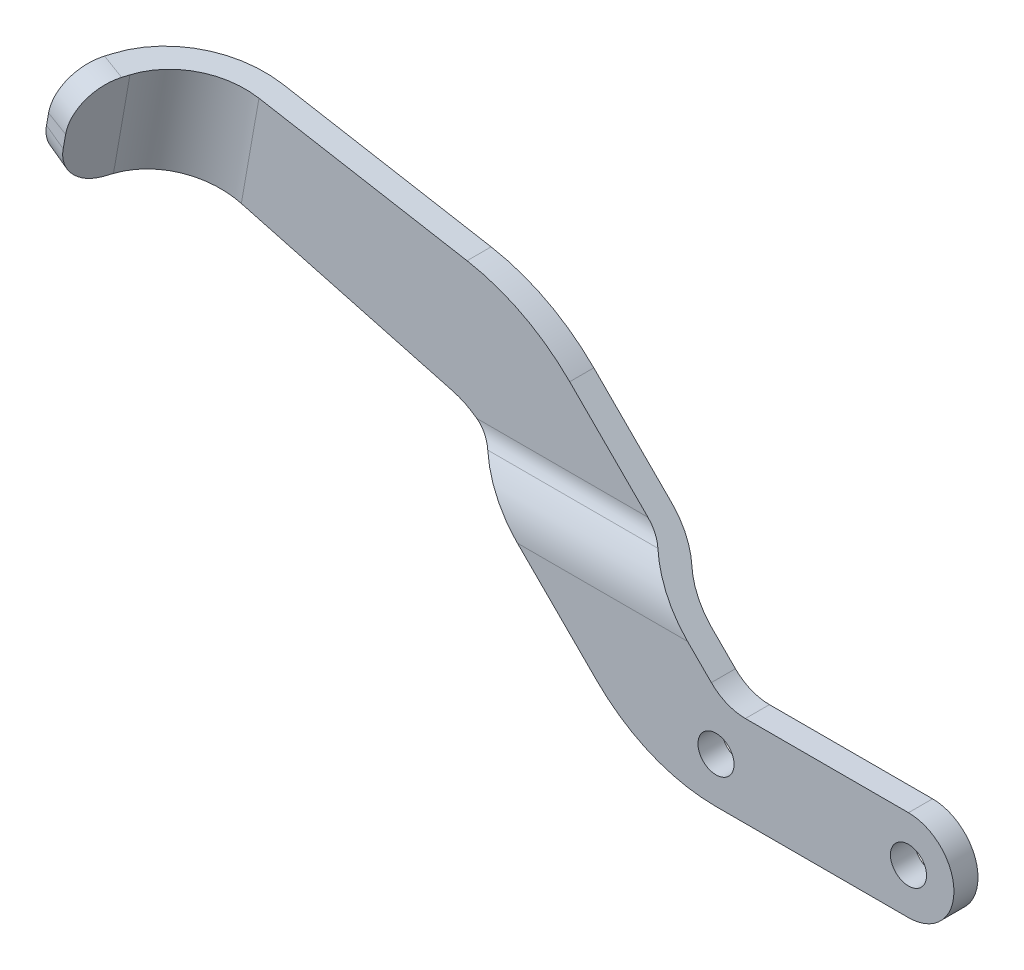
from build123d import *

# Parameters (mm, degrees)
BASE_EXTRUDE_DEPTH      = 3.175
CUT_EXTRUDE1_DEPTH      = 101.324569797
CUT_EXTRUDE1_DEPTH_BACK = 101.324569797
CUT_EXTRUDE2_DEPTH      = 101.3245698
SKETCH4_R               = 2.38125
CUT_EXTRUDE3_DEPTH      = 101.47517694
BOSS_EXTRUDE1_REACH     = 102.663
FILLET4_R               = 5.334


with BuildPart() as part:
    # Sketch1 → Base-Extrude (new, symmetric)
    with BuildSketch(Plane.XY):
        with BuildLine():
            Line((0, 6), (-21.525, 6))
            ThreePointArc((-21.525, 6), (-23.955039796, 6.483364969), (-26.015128061, 7.859871939))
            Line((-26.015128061, 7.859871939), (-47.883548214, 29.728292093))
            ThreePointArc((-47.883548214, 29.728292093), (-54.11564568, 34.297855014), (-61.433396744, 36.781896777))
            Line((-61.433396744, 36.781896777), (-88.9, 41.625))
            Line((-88.9, 41.625), (-91.226630185, 28.43002453))
            Line((-91.226630185, 28.43002453), (-63.378809052, 20.968223346))
            ThreePointArc((-63.378809052, 20.968223346), (-61.081560456, 20.016671822), (-59.108868366, 18.502971942))
            Line((-59.108868366, 18.502971942), (-41.115448212, 0.509551788))
            ThreePointArc((-41.115448212, 0.509551788), (-33.905139284, -4.30822261), (-25.4, -6))
            Line((-25.4, -6), (0, -6))
            ThreePointArc((0, -6), (6, 0), (0, 6))
        make_face()
    extrude(amount=BASE_EXTRUDE_DEPTH, both=True)

    # Sketch2 → Cut-Extrude1 (cut, two sides)
    with BuildSketch(Plane(origin=(0, 0, 0), x_dir=(0, 0, -1), z_dir=(1, 0, 0))) as cut_extrude1_sk:
        with BuildLine():
            Line((109.267936785, -6), (3.175, -6))
            Line((3.175, -6), (0, -6))
            Line((0, -6), (0, 10.999739587))
            ThreePointArc((0, 10.999739587), (0.410118898, 13.244803618), (1.5875, 15.199869794))
            ThreePointArc((1.5875, 15.199869794), (2.764881102, 17.15493597), (3.175, 19.4))
            Line((3.175, 19.4), (3.175, 125.492936785))
            Line((3.175, 125.492936785), (168.312411522, 258.731370649))
            Line((168.312411522, 258.731370649), (274.405348307, 127.238433864))
            Line((274.405348307, 127.238433864), (109.267936785, -6))
        make_face()
    extrude(amount=CUT_EXTRUDE1_DEPTH, mode=Mode.SUBTRACT)
    extrude(cut_extrude1_sk.sketch, amount=-CUT_EXTRUDE1_DEPTH_BACK, mode=Mode.SUBTRACT)

    # Sketch3 → Cut-Extrude2 (cut, through all)
    with BuildSketch(Plane(origin=(0, 0, 0), x_dir=(0, 0, -1), z_dir=(1, 0, 0))):
        with BuildLine():
            Line((0, 19.4), (0, 41.625))
            Line((0, 41.625), (-3.175, 41.625))
            Line((-3.175, 41.625), (-3.175, 10.999739587))
            ThreePointArc((-3.175, 10.999739587), (-2.559821652, 14.367335633), (-0.79375, 17.299934897))
            ThreePointArc((-0.79375, 17.299934897), (-0.205059449, 18.277467985), (0, 19.4))
        make_face()
    extrude(amount=-CUT_EXTRUDE2_DEPTH, mode=Mode.SUBTRACT)

    # Sketch4 → Cut-Extrude3 (cut, through all)
    with BuildSketch(Plane.XY.offset(3.175)):
        Circle(SKETCH4_R)
        with Locations((-25.4, 0)):
            Circle(SKETCH4_R)
    extrude(amount=-CUT_EXTRUDE3_DEPTH, mode=Mode.SUBTRACT)

    # Boss-Extrude1: up to this plane
    boss_extrude1_end = Plane(origin=(-63.378809052, 20.968223346, 3.175), z_dir=(-0.2588190451025212, -0.9659258262890683, 0))
    # Sketch6 → Boss-Extrude1 (add, up to the surface)
    with BuildSketch(Plane(origin=(4.437631227, 25.167057299, 0), x_dir=(-0.9848077530122081, 0.1736481776669304, 0), z_dir=(0.17364817766693036, 0.984807753012208, 0)), mode=Mode.PRIVATE) as boss_extrude1_sk1:
        with BuildLine():
            Line((94.777514638, -3.175), (94.777514638, 0))
            ThreePointArc((94.777514638, 0), (100.893829519, 2.100047584), (104.430088098, 7.51432342))
            Line((104.430088098, 7.51432342), (105.962866768, 13.571805745))
            Line((105.962866768, 13.571805745), (109.040855754, 12.792954794))
            Line((109.040855754, 12.792954794), (107.508077084, 6.73547247))
            ThreePointArc((107.508077084, 6.73547247), (102.844185029, -0.405294385), (94.777514638, -3.175))
        make_face()
    boss_extrude1_tool1 = split(extrude(boss_extrude1_sk1.sketch, amount=-BOSS_EXTRUDE1_REACH, mode=Mode.PRIVATE), bisect_by=boss_extrude1_end, keep=Keep.BOTH, mode=Mode.PRIVATE)
    add(boss_extrude1_tool1.solids().sort_by_distance((-96.950625, 43.044542, 3.972737))[0])

    # Fillet4
    fillet4_edges = [part.edges().sort_by_distance(p)[0] for p in [
        (-103.564353975, 31.735907656, 13.182380269),
        (-101.431035206, 43.834559603, 13.182380269),
    ]]
    fillet(fillet4_edges, radius=FILLET4_R)


solid = part.part
